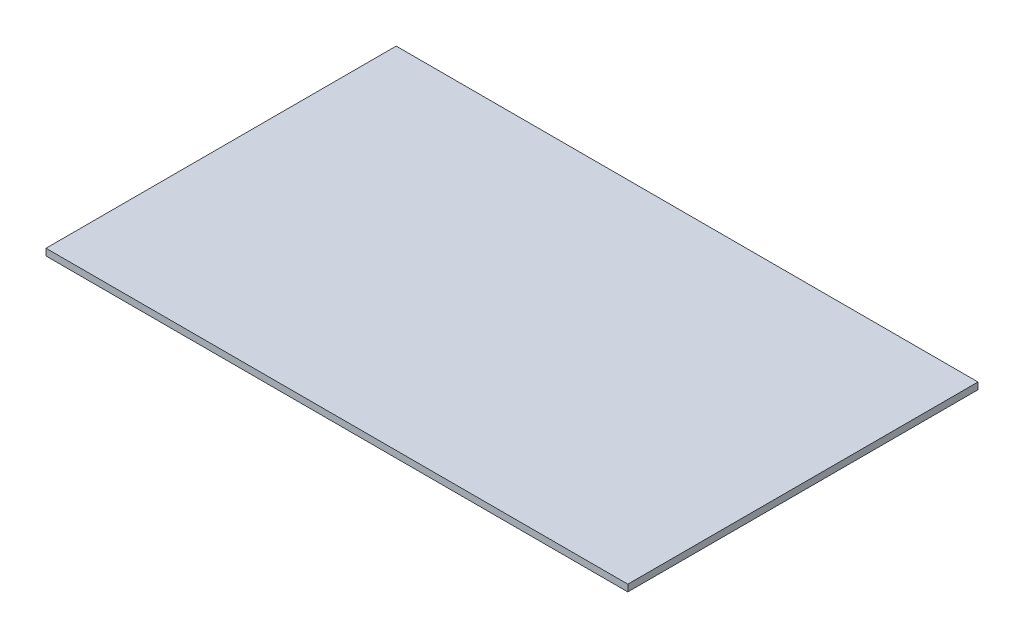
from build123d import *

# Parameters (mm, degrees)
SKETCH1_W           = 86.4
SKETCH1_H           = 52
BOSS_EXTRUDE1_DEPTH = 1


with BuildPart() as part:
    # Sketch1 → Boss-Extrude1 (new body)
    with BuildSketch(Plane(origin=(0, 0, 0), x_dir=(1, 0, 0), z_dir=(0, 1, 0))):
        with Locations((13.082695597, -18.051187648)):
            Rectangle(SKETCH1_W, SKETCH1_H)
    extrude(amount=BOSS_EXTRUDE1_DEPTH)


solid = part.part
